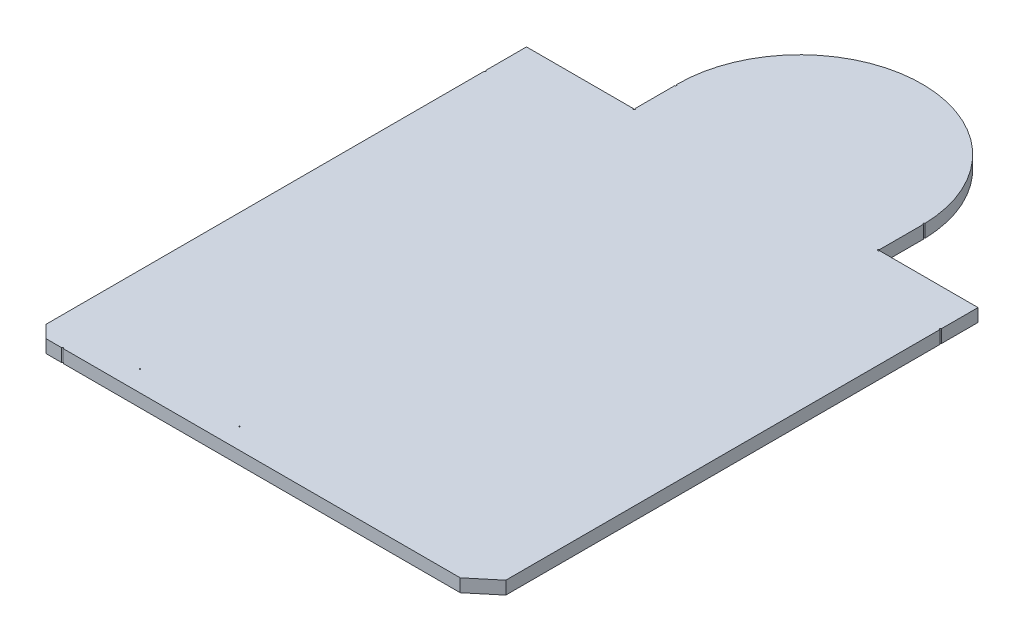
from build123d import *

# Parameters (mm, degrees)
BOSS_EXTRUDE2_DEPTH = 1.5875


with BuildPart() as part:
    # Sketch3 → Boss-Extrude2 (new body)
    with BuildSketch(Plane(origin=(0, 30.53923904, 0), x_dir=(1, 0, 0), z_dir=(0, 1, 0))):
        with BuildLine():
            Line((46.80302417, -93.183255051), (46.80302417, -40.04646156))
            ThreePointArc((46.80302417, -40.04646156), (46.731182121, -40.016703609), (46.70142417, -39.94486156))
            ThreePointArc((46.70142417, -39.94486156), (46.731182121, -39.873019511), (46.80302417, -39.84326156))
            Line((46.80302417, -39.84326156), (46.80302417, -35.47446156))
            Line((46.80302417, -35.47446156), (46.80302417, -35.37286156))
            Line((46.80302417, -35.37286156), (46.70142417, -35.37286156))
            Line((46.70142417, -35.37286156), (34.71262417, -35.37286156))
            ThreePointArc((34.71262417, -35.37286156), (34.682866219, -35.444703609), (34.61102417, -35.47446156))
            ThreePointArc((34.61102417, -35.47446156), (34.539182121, -35.444703609), (34.50942417, -35.37286156))
            ThreePointArc((34.50942417, -35.37286156), (34.539182121, -35.301019511), (34.61102417, -35.27126156))
            Line((34.61102417, -35.27126156), (34.61102417, -29.88558893))
            ThreePointArc((34.61102417, -29.88558893), (34.539486295, -29.856142778), (34.50942417, -29.78486156))
            ThreePointArc((34.50942417, -29.78486156), (34.538144807, -29.713208308), (34.608937785, -29.682428156))
            ThreePointArc((34.608937785, -29.682428156), (19.371024177, -15.05286156), (4.637638035, -30.190416274))
            ThreePointArc((4.637638035, -30.190416274), (4.710051866, -30.219375736), (4.74059877, -30.29113436))
            ThreePointArc((4.74059877, -30.29113436), (4.711156288, -30.363523135), (4.63902417, -30.39358893))
            Line((4.63902417, -30.39358893), (4.63902417, -35.27126156))
            ThreePointArc((4.63902417, -35.27126156), (4.710866219, -35.301019511), (4.74062417, -35.37286156))
            ThreePointArc((4.74062417, -35.37286156), (4.710866219, -35.444703609), (4.63902417, -35.47446156))
            ThreePointArc((4.63902417, -35.47446156), (4.567182121, -35.444703609), (4.53742417, -35.37286156))
            Line((4.53742417, -35.37286156), (-8.46737583, -35.37286156))
            Line((-8.46737583, -35.37286156), (-8.56897583, -35.37286156))
            Line((-8.56897583, -35.37286156), (-8.56897583, -35.47446156))
            Line((-8.56897583, -35.47446156), (-8.56897583, -40.35126156))
            ThreePointArc((-8.56897583, -40.35126156), (-8.497133781, -40.381019511), (-8.46737583, -40.45286156))
            ThreePointArc((-8.46737583, -40.45286156), (-8.497133781, -40.524703609), (-8.56897583, -40.55446156))
            Line((-8.56897583, -40.55446156), (-8.56897583, -94.199276903))
            Line((-8.56897583, -94.199276903), (-8.56897583, -94.30086156))
            Line((-8.56897583, -94.30086156), (-8.497133781, -94.372703609))
            Line((-8.497133781, -94.372703609), (-7.116817879, -95.753019511))
            Line((-7.116817879, -95.753019511), (-7.04497583, -95.82486156))
            Line((-7.04497583, -95.82486156), (-6.943391173, -95.82486156))
            Line((-6.943391173, -95.82486156), (-5.11457583, -95.82486156))
            ThreePointArc((-5.11457583, -95.82486156), (-5.084817879, -95.753019511), (-5.01297583, -95.72326156))
            ThreePointArc((-5.01297583, -95.72326156), (-4.941133781, -95.753019511), (-4.91137583, -95.82486156))
            Line((-4.91137583, -95.82486156), (1.94703057, -95.82486156))
            Line((1.94703057, -95.82486156), (13.98703057, -95.82486156))
            Line((13.98703057, -95.82486156), (43.653417661, -95.82486156))
            Line((43.653417661, -95.82486156), (43.75502417, -95.82486156))
            Line((43.75502417, -95.82486156), (43.833075452, -95.759818825))
            Line((43.833075452, -95.759818825), (46.724972888, -93.349904295))
            Line((46.724972888, -93.349904295), (46.80302417, -93.28486156))
            Line((46.80302417, -93.28486156), (46.80302417, -93.183255051))
        make_face()
        with BuildLine():
            ThreePointArc((2.01053057, -93.28486156), (1.99193185, -93.329762841), (1.94703057, -93.34836156))
            ThreePointArc((1.94703057, -93.34836156), (1.902129289, -93.329762841), (1.88353057, -93.28486156))
            ThreePointArc((1.88353057, -93.28486156), (1.902129289, -93.239960279), (1.94703057, -93.22136156))
            ThreePointArc((1.94703057, -93.22136156), (1.99193185, -93.239960279), (2.01053057, -93.28486156))
        make_face(mode=Mode.SUBTRACT)
        with BuildLine():
            ThreePointArc((14.21053157, -93.28486156), (14.19193285, -93.329762841), (14.14703157, -93.34836156))
            ThreePointArc((14.14703157, -93.34836156), (14.102130289, -93.329762841), (14.08353157, -93.28486156))
            ThreePointArc((14.08353157, -93.28486156), (14.102130289, -93.239960279), (14.14703157, -93.22136156))
            ThreePointArc((14.14703157, -93.22136156), (14.19193285, -93.239960279), (14.21053157, -93.28486156))
        make_face(mode=Mode.SUBTRACT)
    extrude(amount=BOSS_EXTRUDE2_DEPTH)


solid = part.part
